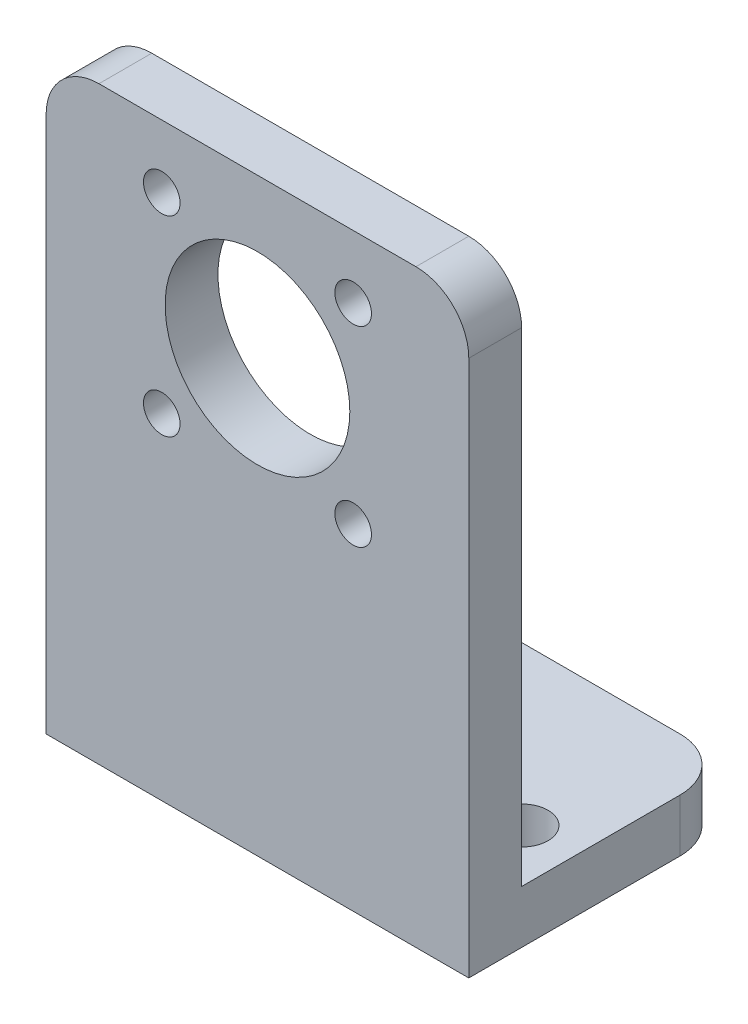
from build123d import *

# Parameters (mm, degrees)
SKETCH1_W                      = 25.4
SKETCH1_H                      = 35.433
SKETCH1_R                      = 5.55
BOSS_EXTRUDE1_DEPTH            = 3.175
SKETCH3_W                      = 25.4
SKETCH3_H                      = 3.175
BOSS_EXTRUDE2_DEPTH            = 12.7
FILLET1_R                      = 3.175
M2_CLEARANCE_HOLE1_D           = 2.2
F_4_CLEARANCE_HOLE1_D          = 2.9464
F_1_8_0_1250_DOWEL_HOLE1_D     = 3.175
F_1_8_0_1250_DOWEL_HOLE1_DEPTH = 4.064
F_1_8_0_1250_DOWEL_HOLE1_TIP   = 0.953866233


with BuildPart() as part:
    # Sketch1 → Boss-Extrude1 (new body)
    with BuildSketch(Plane.XY):
        with Locations((0, -8.1915)):
            Rectangle(SKETCH1_W, SKETCH1_H)
        Circle(SKETCH1_R, mode=Mode.SUBTRACT)
    extrude(amount=BOSS_EXTRUDE1_DEPTH)

    # Sketch3 → Boss-Extrude2 (add)
    with BuildSketch(Plane(origin=(0, 0, 0), x_dir=(-1, 0, 0), z_dir=(0, 0, -1))):
        with Locations((0, -24.3205)):
            Rectangle(SKETCH3_W, SKETCH3_H)
    extrude(amount=BOSS_EXTRUDE2_DEPTH)

    # Fillet1
    fillet1_edges = [part.edges().sort_by_distance(p)[0] for p in [
        (-12.7, -24.3205, -12.7),
        (12.7, -24.3205, -12.7),
        (-12.7, 9.525, 1.5875),
        (12.7, 9.525, 1.5875),
    ]]
    fillet(fillet1_edges, radius=FILLET1_R)

    # M2 Clearance Hole1 (through all)
    with Locations(Plane(origin=(0, -25.908, 3.175), x_dir=(1, 0, 0), z_dir=(0, 0, 1))):
        with Locations((5.75, 31.658), (-5.75, 31.658), (5.75, 20.158), (-5.75, 20.158)):
            Hole(M2_CLEARANCE_HOLE1_D / 2)

    # #4 Clearance Hole1 (through all)
    with Locations(Plane(origin=(0, -22.733, 0), x_dir=(1, 0, 0), z_dir=(0, 1, 0))):
        with Locations((0, 9.525)):
            Hole(F_4_CLEARANCE_HOLE1_D / 2)

    # 1/8 (0.1250) Dowel Hole1
    with Locations(Plane(origin=(0, -22.733, 0), x_dir=(1, 0, 0), z_dir=(0, 1, 0))):
        with Locations((9.525, 3.175), (-9.525, 3.175)):
            Hole(F_1_8_0_1250_DOWEL_HOLE1_D / 2, depth=F_1_8_0_1250_DOWEL_HOLE1_DEPTH)
            with Locations((0, 0, -(F_1_8_0_1250_DOWEL_HOLE1_DEPTH + F_1_8_0_1250_DOWEL_HOLE1_TIP / 2))):  # 118° drill point
                Cone(0, F_1_8_0_1250_DOWEL_HOLE1_D / 2, F_1_8_0_1250_DOWEL_HOLE1_TIP, mode=Mode.SUBTRACT)


solid = part.part
